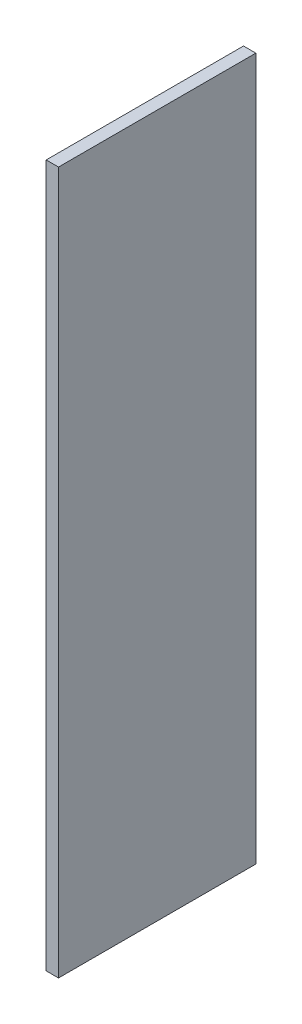
from build123d import *

# Parameters (mm, degrees)
SKETCH1_W           = 288
SKETCH1_H           = 1025
BOSS_EXTRUDE1_DEPTH = 18


with BuildPart() as part:
    # Sketch1 → Boss-Extrude1 (new body)
    with BuildSketch(Plane(origin=(0, 0, 0), x_dir=(0, 0, -1), z_dir=(1, 0, 0))):
        with Locations((-123.607933189, -454.719556499)):
            Rectangle(SKETCH1_W, SKETCH1_H)
    extrude(amount=BOSS_EXTRUDE1_DEPTH)


solid = part.part
